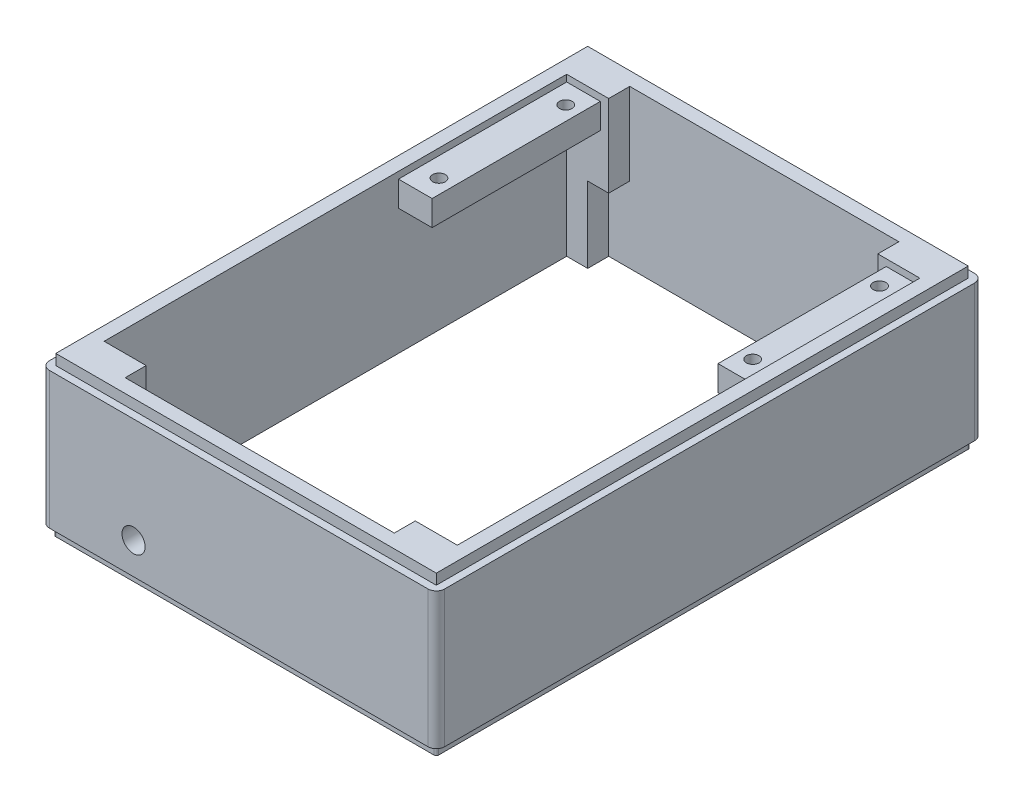
from build123d import *

# Parameters (mm, degrees)
SKETCH1_W                      = 94
SKETCH1_H                      = 130
BOSS_EXTRUDE1_DEPTH            = 35
SKETCH2_W                      = 90.5
SKETCH2_H                      = 126.5
BOSS_EXTRUDE2_DEPTH            = 2.5
CUT_EXTRUDE1_DEPTH             = 38.5
SKETCH4_W                      = 5
SKETCH4_H                      = 18
CUT_EXTRUDE2_DEPTH             = 5
SKETCH9_W                      = 5
SKETCH9_H                      = 18
CUT_EXTRUDE6_DEPTH             = 5
SKETCH11_W                     = 5
SKETCH11_H                     = 5
CUT_EXTRUDE8_DEPTH             = 18
SKETCH12_W                     = 5
SKETCH12_H                     = 18
CUT_EXTRUDE9_DEPTH             = 5
F_5_5_5_5_DIAMETER_HOLE1_D     = 5.5
F_5_5_5_5_DIAMETER_HOLE1_DEPTH = 5
FILLET1_R                      = 2
CUT_EXTRUDE10_DEPTH            = 2.5
SKETCH17_W                     = 40
SKETCH17_H                     = 6
BOSS_EXTRUDE3_DEPTH            = 8
SKETCH18_W                     = 40
SKETCH18_H                     = 6
BOSS_EXTRUDE4_DEPTH            = 8
SKETCH23_R                     = 1.5
CUT_EXTRUDE11_DEPTH            = 4.4


with BuildPart() as part:
    # Sketch1 → Boss-Extrude1 (new body)
    with BuildSketch(Plane.XZ):
        with Locations((47, -65)):
            Rectangle(SKETCH1_W, SKETCH1_H)
    extrude(amount=-BOSS_EXTRUDE1_DEPTH)

    # Sketch2 → Boss-Extrude2 (add)
    with BuildSketch(Plane(origin=(0, 35, 0), x_dir=(-1, 0, 0), z_dir=(0, 1, 0))):
        with Locations((-47, -65)):
            Rectangle(SKETCH2_W, SKETCH2_H)
    extrude(amount=BOSS_EXTRUDE2_DEPTH)

    # Sketch3 → Cut-Extrude1 (cut, through all)
    with BuildSketch(Plane(origin=(0, 37.5, 0), x_dir=(-1, 0, 0), z_dir=(0, 1, 0))):
        Polygon((-83, -120), (-79, -120), (-79, -125), (-15, -125), (-15, -120), (-5, -120), (-5, -10), (-15, -10), (-15, -5), (-79, -5), (-79, -10), (-89, -10), (-89, -96), (-89, -120), align=None)
    extrude(amount=-CUT_EXTRUDE1_DEPTH, mode=Mode.SUBTRACT)

    # Sketch4 → Cut-Extrude2 (cut)
    with BuildSketch(Plane(origin=(0, 0, -10), x_dir=(-1, 0, 0), z_dir=(0, 0, -1))):
        with Locations((-12.5, 9)):
            Rectangle(SKETCH4_W, SKETCH4_H)
    extrude(amount=-CUT_EXTRUDE2_DEPTH, mode=Mode.SUBTRACT)

    # Sketch9 → Cut-Extrude6 (cut)
    with BuildSketch(Plane(origin=(0, 0, -10), x_dir=(-1, 0, 0), z_dir=(0, 0, -1))):
        with Locations((-81.5, 9)):
            Rectangle(SKETCH9_W, SKETCH9_H)
    extrude(amount=-CUT_EXTRUDE6_DEPTH, mode=Mode.SUBTRACT)

    # Sketch11 → Cut-Extrude8 (cut)
    with BuildSketch(Plane.XZ):
        with Locations((12.5, -122.5)):
            Rectangle(SKETCH11_W, SKETCH11_H)
    extrude(amount=-CUT_EXTRUDE8_DEPTH, mode=Mode.SUBTRACT)

    # Sketch12 → Cut-Extrude9 (cut)
    with BuildSketch(Plane.XY.offset(-120)):
        with Locations((81.5, 9)):
            Rectangle(SKETCH12_W, SKETCH12_H)
    extrude(amount=-CUT_EXTRUDE9_DEPTH, mode=Mode.SUBTRACT)

    # Ø5.5 (5.5) Diameter Hole1
    with Locations(Plane(origin=(0, 0, -5), x_dir=(-1, 0, 0), z_dir=(0, 0, -1))):
        with Locations((-22, 10)):
            Hole(F_5_5_5_5_DIAMETER_HOLE1_D / 2, depth=F_5_5_5_5_DIAMETER_HOLE1_DEPTH)

    # Fillet1
    fillet1_edges = [part.edges().sort_by_distance(p)[0] for p in [
        (94, 17.5, -130),
        (0, 17.5, -130),
        (0, 17.5, 0),
        (94, 17.5, 0),
    ]]
    fillet(fillet1_edges, radius=FILLET1_R)

    # Sketch16 → Cut-Extrude10 (cut)
    with BuildSketch(Plane.XZ):
        with BuildLine():
            Line((0, -2), (0, -128))
            ThreePointArc((0, -128), (0.585786438, -129.414213562), (2, -130))
            Line((2, -130), (92, -130))
            ThreePointArc((92, -130), (93.414213562, -129.414213562), (94, -128))
            Line((94, -128), (94, -2))
            ThreePointArc((94, -2), (93.414213562, -0.585786438), (92, 0))
            Line((92, 0), (2, 0))
            ThreePointArc((2, 0), (0.585786438, -0.585786438), (0, -2))
        make_face()
        with BuildLine():
            Line((1.5, -2), (1.5, -128))
            ThreePointArc((1.5, -128), (1.646446609, -128.353553391), (2, -128.5))
            Line((2, -128.5), (92, -128.5))
            ThreePointArc((92, -128.5), (92.353553391, -128.353553391), (92.5, -128))
            Line((92.5, -128), (92.5, -2))
            ThreePointArc((92.5, -2), (92.353553391, -1.646446609), (92, -1.5))
            Line((92, -1.5), (2, -1.5))
            ThreePointArc((2, -1.5), (1.646446609, -1.646446609), (1.5, -2))
        make_face(mode=Mode.SUBTRACT)
    extrude(amount=-CUT_EXTRUDE10_DEPTH, mode=Mode.SUBTRACT)

    # Sketch17 → Boss-Extrude3 (add)
    with BuildSketch(Plane(origin=(5, 0, 0), x_dir=(0, 0, -1), z_dir=(1, 0, 0))):
        with Locations((100, 32.9)):
            Rectangle(SKETCH17_W, SKETCH17_H)
    extrude(amount=BOSS_EXTRUDE3_DEPTH)

    # Sketch18 → Boss-Extrude4 (add)
    with BuildSketch(Plane.ZY.offset(-89)):
        with Locations((-100, 32.9)):
            Rectangle(SKETCH18_W, SKETCH18_H)
    extrude(amount=BOSS_EXTRUDE4_DEPTH)

    # Sketch23 → Cut-Extrude11 (cut)
    with BuildSketch(Plane(origin=(0, 35.9, 0), x_dir=(1, 0, 0), z_dir=(0, 1, 0))):
        with Locations((9.61875, 115.175)):
            Circle(SKETCH23_R)
        with Locations((9.61875, 85.0125)):
            Circle(SKETCH23_R)
        with Locations((84.23125, 115.175)):
            Circle(SKETCH23_R)
        with Locations((84.23125, 85.0125)):
            Circle(SKETCH23_R)
    extrude(amount=-CUT_EXTRUDE11_DEPTH, mode=Mode.SUBTRACT)


solid = part.part
